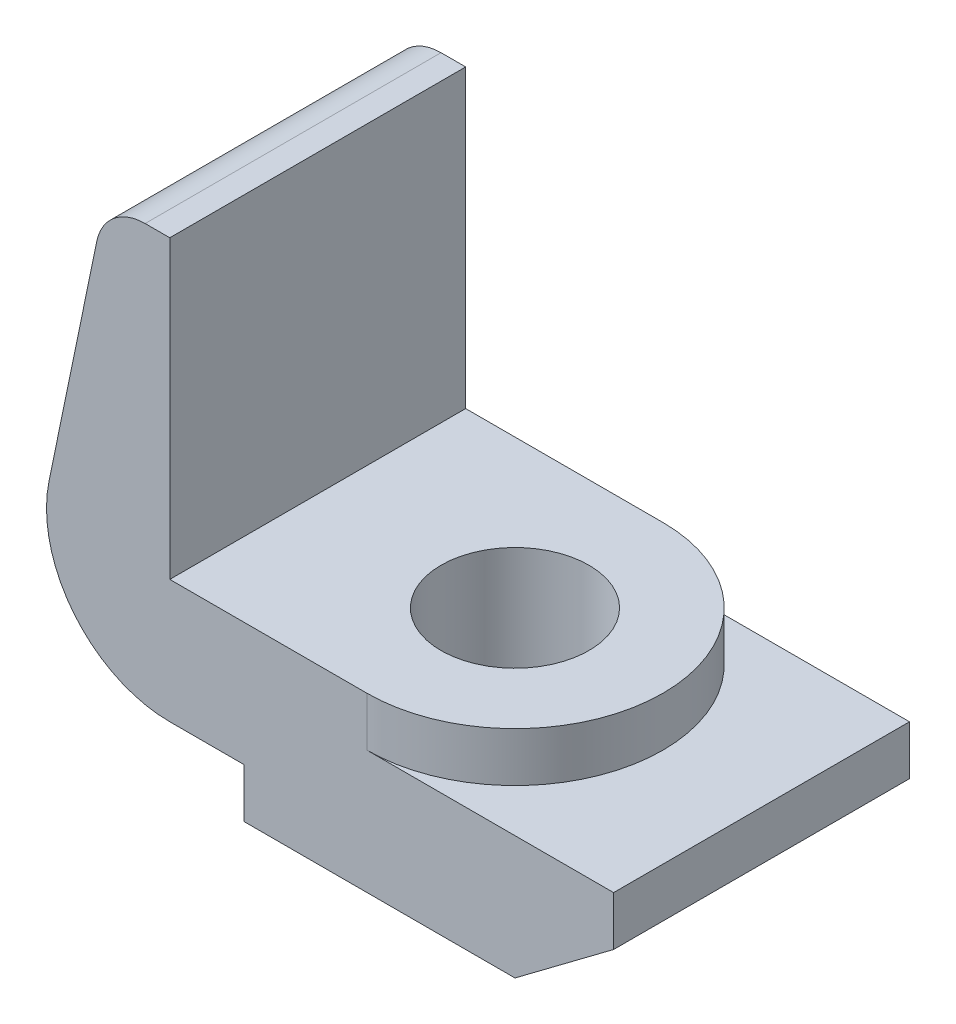
from build123d import *

# Parameters (mm, degrees)
BOSS_EXTRUDE1_DEPTH = 76.2
SKETCH2_R           = 38.1
BOSS_EXTRUDE2_DEPTH = 12.7
SKETCH3_R           = 19.05
CUT_EXTRUDE1_DEPTH  = 45.45
BOSS_EXTRUDE3_DEPTH = 76.2


with BuildPart() as part:
    # Sketch1 → Boss-Extrude1 (new body)
    with BuildSketch(Plane.XY):
        Polygon((0, 0), (69.85, 0), (95.25, 19.05), (95.25, 31.75), (31.75, 31.75), (31.75, 44.45), (-19.05, 44.45), (-19.05, 12.7), (0, 12.7), align=None)
    extrude(amount=BOSS_EXTRUDE1_DEPTH)

    # Sketch2 → Boss-Extrude2 (add, through all)
    with BuildSketch(Plane(origin=(0, 31.75, 0), x_dir=(1, 0, 0), z_dir=(0, 1, 0))):
        with Locations((31.75, -38.1)):
            Circle(SKETCH2_R)
    extrude(amount=BOSS_EXTRUDE2_DEPTH)

    # Sketch3 → Cut-Extrude1 (cut, through all)
    with BuildSketch(Plane(origin=(0, 44.45, 0), x_dir=(1, 0, 0), z_dir=(0, 1, 0))):
        with Locations((31.75, -38.1)):
            Circle(SKETCH3_R)
    extrude(amount=-CUT_EXTRUDE1_DEPTH, mode=Mode.SUBTRACT)

    # Sketch4 → Boss-Extrude3 (add, through all)
    with BuildSketch(Plane.XY.offset(76.2)):
        with BuildLine():
            Line((-19.05, 44.45), (-19.05, 120.65))
            Line((-19.05, 120.65), (-25.4, 120.65))
            ThreePointArc((-25.4, 120.65), (-33.421823369, 117.795829058), (-37.838031752, 110.516196825))
            Line((-37.838031752, 110.516196825), (-50.145079379, 50.865492062))
            ThreePointArc((-50.145079379, 50.865492062), (-43.664572645, 24.395441578), (-19.05, 12.7))
            Line((-19.05, 12.7), (-19.05, 44.45))
        make_face()
    extrude(amount=-BOSS_EXTRUDE3_DEPTH)


solid = part.part
